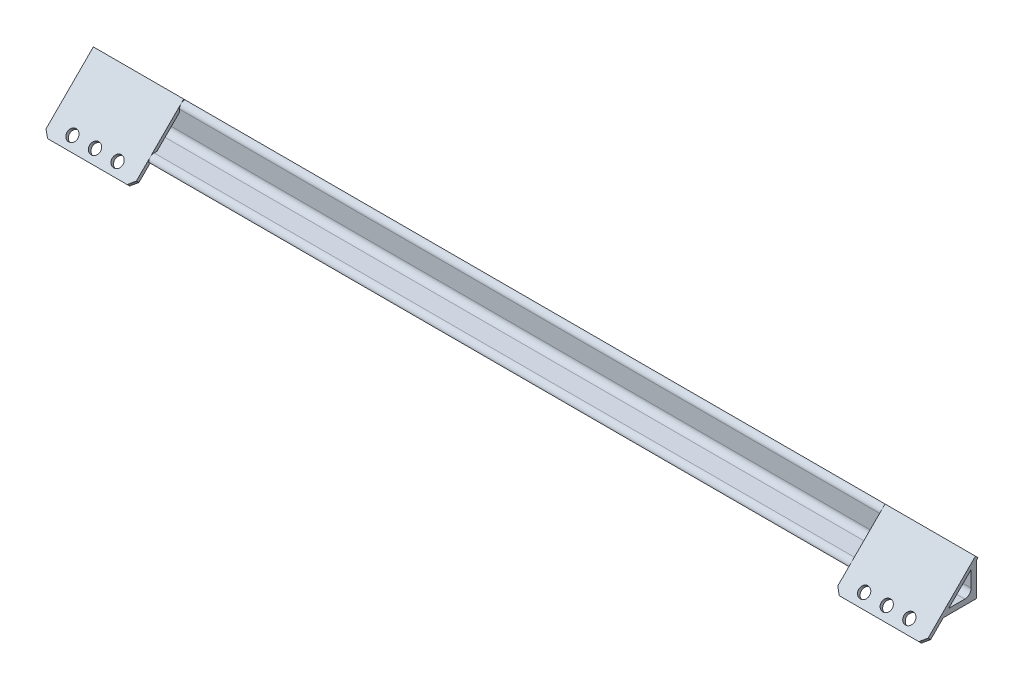
from build123d import *

# Parameters (mm, degrees)
HIERRO_ANGULAR_20_X_20_X_3_1_DEPTH = 488
CROQUIS3_W                         = 50
CROQUIS3_H                         = 40.041630561
CROQUIS3_R                         = 3
SALIENTE_EXTRUIR1_DEPTH            = 2
CHAFL_N1_SIZE                      = 3
CHAFL_N1_OF_SIMETR_A3_SIZE         = 3


with BuildPart() as part:
    # Sketch1 → Hierro angular 20 X 20 X 3(1) (new body)
    with BuildSketch(Plane.YZ.offset(-244)):
        with BuildLine():
            Line((0, 0), (0, 20))
            ThreePointArc((0, 20), (2.121320344, 19.121320344), (3, 17))
            Line((3, 17), (3, 6.5))
            ThreePointArc((3, 6.5), (4.025126266, 4.025126266), (6.5, 3))
            Line((6.5, 3), (17, 3))
            ThreePointArc((17, 3), (19.121320344, 2.121320344), (20, 0))
            Line((20, 0), (0, 0))
        make_face()
    extrude(amount=HIERRO_ANGULAR_20_X_20_X_3_1_DEPTH)


with BuildPart() as body_2:
    # Croquis3 → Saliente-Extruir1 (new body)
    with BuildSketch(Plane(origin=(0, 10.621320344, 10.621320344), x_dir=(1, 0, 0), z_dir=(0, 0.7071067811865477, 0.7071067811865475))):
        with Locations((-219, -5.878679656)):
            Rectangle(CROQUIS3_W, CROQUIS3_H)
        with Locations(Location((-206.5, -19.899494937, 0), (0, 0, 270))):
            Circle(CROQUIS3_R, mode=Mode.SUBTRACT)
        with Locations(Location((-219, -19.899494937, 0), (0, 0, 270))):
            Circle(CROQUIS3_R, mode=Mode.SUBTRACT)
        with Locations(Location((-231.5, -19.899494937, 0), (0, 0, 270))):
            Circle(CROQUIS3_R, mode=Mode.SUBTRACT)
    saliente_extruir1 = extrude(amount=-SALIENTE_EXTRUIR1_DEPTH)

    # Chaflán1
    chafl_n1_edges = [body_2.edges().sort_by_distance(p)[0] for p in [
        (-194, -8.399494937, 28.227922061),
        (-244, -8.399494937, 28.227922061),
    ]]
    chamfer(chafl_n1_edges, length=CHAFL_N1_SIZE)


with BuildPart() as part_1:
    add(part.part)

    # Simetría3: Saliente-Extruir1 across plane
    add(saliente_extruir1.mirror(Plane(origin=(0, 0, 0), x_dir=(0, 0, 1), z_dir=(1, 0, 0))))

    # Chaflán1 of Simetría3
    chafl_n1_of_simetr_a3_edges = [part_1.edges().sort_by_distance(p)[0] for p in [
        (194, -8.399494937, 28.227922061),
        (244, -8.399494937, 28.227922061),
    ]]
    chamfer(chafl_n1_of_simetr_a3_edges, length=CHAFL_N1_OF_SIMETR_A3_SIZE)


solid = Compound([body_2.part, part_1.part])
